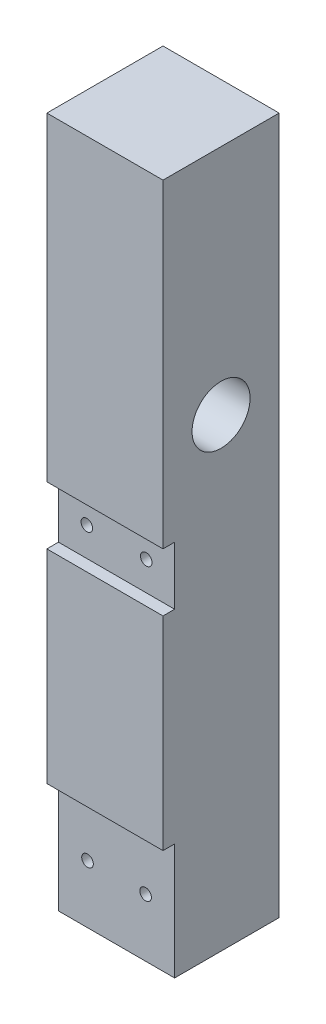
from build123d import *

# Parameters (mm, degrees)
SKETCH1_W           = 20
SKETCH1_H           = 120
SKETCH1_R           = 2.5
BOSS_EXTRUDE2_DEPTH = 20
SKETCH10_R          = 5
CUT_EXTRUDE1_DEPTH  = 10
SKETCH11_R          = 1
CUT_EXTRUDE2_DEPTH  = 21
SKETCH12_R          = 2
CUT_EXTRUDE3_DEPTH  = 5
SKETCH13_R          = 1
CUT_EXTRUDE4_DEPTH  = 21
SKETCH14_R          = 2
CUT_EXTRUDE5_DEPTH  = 5
SKETCH16_W          = 20
SKETCH16_H          = 10
SKETCH16_H_2        = 20
CUT_EXTRUDE6_DEPTH  = 2


with BuildPart() as part:
    # Sketch1 → Boss-Extrude2 (new body)
    with BuildSketch(Plane(origin=(0, 0, 0), x_dir=(0, 0, -1), z_dir=(1, 0, 0))):
        with Locations((10, 60)):
            Rectangle(SKETCH1_W, SKETCH1_H)
        with Locations((10, 80)):
            Circle(SKETCH1_R, mode=Mode.SUBTRACT)
    extrude(amount=-BOSS_EXTRUDE2_DEPTH)

    # Sketch10 → Cut-Extrude1 (cut)
    with BuildSketch(Plane(origin=(0, 0, 0), x_dir=(0, 0, -1), z_dir=(1, 0, 0))):
        with Locations((10, 80)):
            Circle(SKETCH10_R)
    extrude(amount=-CUT_EXTRUDE1_DEPTH, mode=Mode.SUBTRACT)

    # Sketch11 → Cut-Extrude2 (cut, through all)
    with BuildSketch(Plane.XY):
        with Locations((-15, 10)):
            Circle(SKETCH11_R)
        with Locations((-5, 10)):
            Circle(SKETCH11_R)
    extrude(amount=-CUT_EXTRUDE2_DEPTH, mode=Mode.SUBTRACT)

    # Sketch12 → Cut-Extrude3 (cut)
    with BuildSketch(Plane(origin=(0, 0, -20), x_dir=(-1, 0, 0), z_dir=(0, 0, -1))):
        with Locations((5, 10)):
            Circle(SKETCH12_R)
        with Locations((15, 10)):
            Circle(SKETCH12_R)
    extrude(amount=-CUT_EXTRUDE3_DEPTH, mode=Mode.SUBTRACT)

    # Sketch13 → Cut-Extrude4 (cut, through all)
    with BuildSketch(Plane(origin=(0, 0, -20), x_dir=(-1, 0, 0), z_dir=(0, 0, -1))):
        with Locations((4.880538742, 60)):
            Circle(SKETCH13_R)
        with Locations((15.119461258, 60)):
            Circle(SKETCH13_R)
    extrude(amount=-CUT_EXTRUDE4_DEPTH, mode=Mode.SUBTRACT)

    # Sketch14 → Cut-Extrude5 (cut)
    with BuildSketch(Plane(origin=(0, 0, -20), x_dir=(-1, 0, 0), z_dir=(0, 0, -1))):
        with Locations((4.880538742, 60)):
            Circle(SKETCH14_R)
        with Locations((15.119461258, 60)):
            Circle(SKETCH14_R)
    extrude(amount=-CUT_EXTRUDE5_DEPTH, mode=Mode.SUBTRACT)

    # Sketch16 → Cut-Extrude6 (cut)
    with BuildSketch(Plane.XY):
        with Locations((-10, 60)):
            Rectangle(SKETCH16_W, SKETCH16_H)
        with Locations((-10, 10)):
            Rectangle(SKETCH16_W, SKETCH16_H_2)
    extrude(amount=-CUT_EXTRUDE6_DEPTH, mode=Mode.SUBTRACT)


solid = part.part
